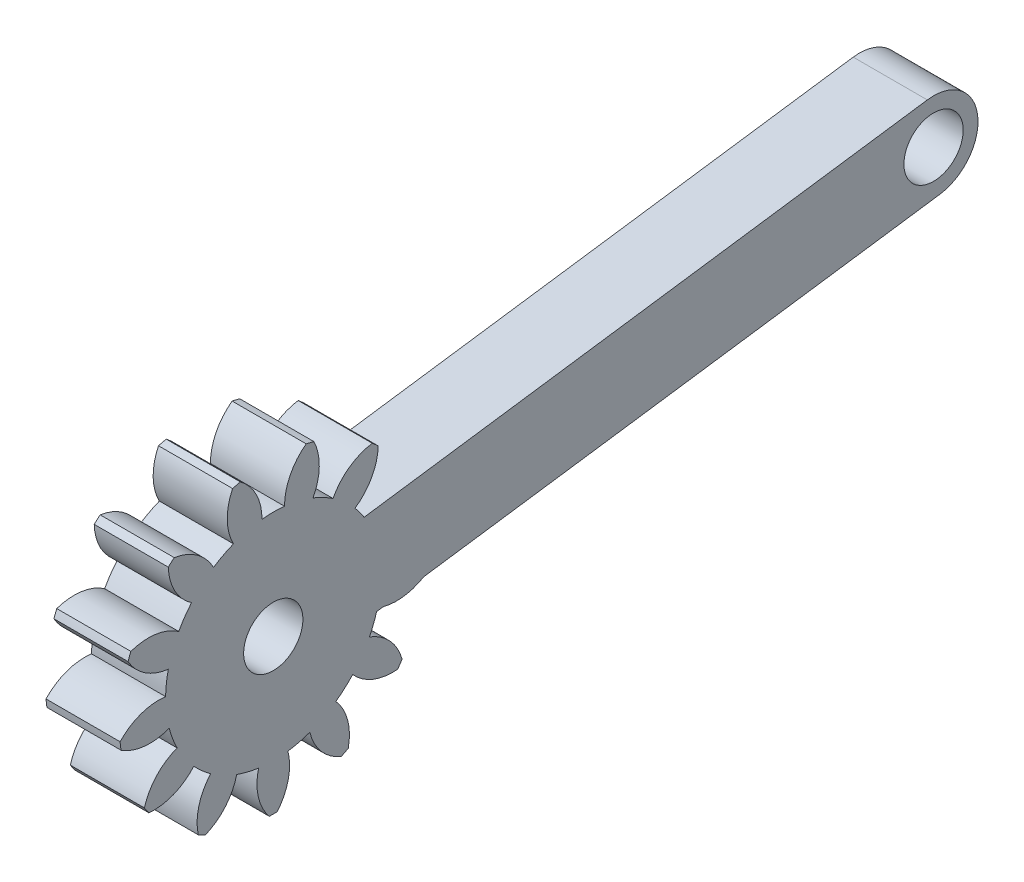
from build123d import *

# Parameters (mm, degrees)
SKETCH1_R           = 2
BOSS_EXTRUDE1_DEPTH = 5
SKETCH2_R           = 2
BOSS_EXTRUDE2_DEPTH = 5


with BuildPart() as part:
    # Sketch1 → Boss-Extrude1 (new body)
    with BuildSketch(Plane(origin=(-2.712826585, 0, 0), x_dir=(0, 0, -1), z_dir=(1, 0, 0))):
        with BuildLine():
            ThreePointArc((-81.47562753, 41.343615563), (-81.034251259, 39.725922602), (-79.907831624, 38.483778355))
            ThreePointArc((-79.907831624, 38.483778355), (-80.372835078, 37.880397724), (-80.772113271, 37.231650221))
            ThreePointArc((-80.772113271, 37.231650221), (-82.332972226, 37.844400456), (-84.002055602, 37.683452608))
            ThreePointArc((-84.002055602, 37.683452608), (-84.100262161, 37.43424746), (-84.192007076, 37.182591734))
            ThreePointArc((-84.192007076, 37.182591734), (-83.049408394, 35.955313535), (-81.474760125, 35.378922733))
            ThreePointArc((-81.474760125, 35.378922733), (-81.606095275, 34.628557837), (-81.65815056, 33.868566623))
            ThreePointArc((-81.65815056, 33.868566623), (-83.324981759, 33.685762686), (-84.728085497, 32.767588723))
            ThreePointArc((-84.728085497, 32.767588723), (-84.69923168, 32.50128966), (-84.663517521, 32.235823593))
            ThreePointArc((-84.663517521, 32.235823593), (-83.081452015, 31.6801148), (-81.419308055, 31.901521629))
            ThreePointArc((-81.419308055, 31.901521629), (-81.1868876, 31.176072024), (-80.879794738, 30.478941927))
            ThreePointArc((-80.879794738, 30.478941927), (-82.270747242, 29.542461997), (-83.086437186, 28.077404509))
            ThreePointArc((-83.086437186, 28.077404509), (-82.937133053, 27.855017437), (-82.782141503, 27.636556105))
            ThreePointArc((-82.782141503, 27.636556105), (-81.123041315, 27.879722907), (-79.754178815, 28.848205731))
            ThreePointArc((-79.754178815, 28.848205731), (-79.211247481, 28.313863177), (-78.615357745, 27.839298301))
            ThreePointArc((-78.615357745, 27.839298301), (-79.411781098, 26.363678645), (-79.45319251, 24.687364646))
            ThreePointArc((-79.45319251, 24.687364646), (-79.217641841, 24.559835763), (-78.978879596, 24.438426025))
            ThreePointArc((-78.978879596, 24.438426025), (-77.622824585, 25.424761837), (-76.860833445, 26.918452913))
            ThreePointArc((-76.860833445, 26.918452913), (-76.131770258, 26.697628851), (-75.383594806, 26.55434629))
            ThreePointArc((-75.383594806, 26.55434629), (-75.403038015, 24.877633587), (-74.660684041, 23.374086413))
            ThreePointArc((-74.660684041, 23.374086413), (-74.392848655, 23.370631049), (-74.125013268, 23.374086413))
            ThreePointArc((-74.125013268, 23.374086413), (-73.382659294, 24.877633587), (-73.402102503, 26.55434629))
            ThreePointArc((-73.402102503, 26.55434629), (-72.653927052, 26.697628851), (-71.924863864, 26.918452913))
            ThreePointArc((-71.924863864, 26.918452913), (-71.162872724, 25.424761837), (-69.806817713, 24.438426025))
            ThreePointArc((-69.806817713, 24.438426025), (-69.568055468, 24.559835763), (-69.332504799, 24.687364646))
            ThreePointArc((-69.332504799, 24.687364646), (-69.373916212, 26.363678645), (-70.170339564, 27.839298301))
            ThreePointArc((-70.170339564, 27.839298301), (-69.574449829, 28.313863177), (-69.031518494, 28.848205731))
            ThreePointArc((-69.031518494, 28.848205731), (-67.662655994, 27.879722907), (-66.003555806, 27.636556105))
            ThreePointArc((-66.003555806, 27.636556105), (-65.848564256, 27.855017437), (-65.699260124, 28.077404509))
            ThreePointArc((-65.699260124, 28.077404509), (-66.514950067, 29.542461997), (-67.905902571, 30.478941927))
            ThreePointArc((-67.905902571, 30.478941927), (-67.598809709, 31.176072024), (-67.366389254, 31.901521629))
            ThreePointArc((-67.366389254, 31.901521629), (-65.704245294, 31.6801148), (-64.122179788, 32.235823593))
            ThreePointArc((-64.122179788, 32.235823593), (-64.086465629, 32.50128966), (-64.057611812, 32.767588723))
            ThreePointArc((-64.057611812, 32.767588723), (-65.46071555, 33.685762686), (-67.12754675, 33.868566623))
            ThreePointArc((-67.12754675, 33.868566623), (-67.179602034, 34.628557837), (-67.310937184, 35.378922733))
            ThreePointArc((-67.310937184, 35.378922733), (-65.736288915, 35.955313535), (-64.593690233, 37.182591734))
            ThreePointArc((-64.593690233, 37.182591734), (-64.685435149, 37.43424746), (-64.783641707, 37.683452608))
            ThreePointArc((-64.783641707, 37.683452608), (-66.452725084, 37.844400456), (-68.013584038, 37.231650221))
            ThreePointArc((-68.013584038, 37.231650221), (-68.412862231, 37.880397724), (-68.877865686, 38.483778355))
            ThreePointArc((-68.877865686, 38.483778355), (-67.75144605, 39.725922602), (-67.31006978, 41.343615563))
            ThreePointArc((-67.31006978, 41.343615563), (-67.508256115, 41.523809654), (-67.711025111, 41.69883099))
            ThreePointArc((-67.711025111, 41.69883099), (-69.263721238, 41.065681511), (-70.361033972, 39.797750798))
            ThreePointArc((-70.361033972, 39.797750798), (-71.016065252, 40.186634356), (-71.708210323, 40.504803491))
            ThreePointArc((-71.708210323, 40.504803491), (-71.288068484, 42.128140906), (-71.64902861, 43.765654666))
            ThreePointArc((-71.64902861, 43.765654666), (-71.908254264, 43.833106827), (-72.169133764, 43.893849073))
            ThreePointArc((-72.169133764, 43.893849073), (-73.249738671, 42.611649181), (-73.632124061, 40.979005638))
            ThreePointArc((-73.632124061, 40.979005638), (-74.392848655, 41.018936713), (-75.153573248, 40.979005638))
            ThreePointArc((-75.153573248, 40.979005638), (-75.535958638, 42.611649181), (-76.616563545, 43.893849073))
            ThreePointArc((-76.616563545, 43.893849073), (-76.877443045, 43.833106827), (-77.1366687, 43.765654666))
            ThreePointArc((-77.1366687, 43.765654666), (-77.497628825, 42.128140906), (-77.077486986, 40.504803491))
            ThreePointArc((-77.077486986, 40.504803491), (-77.769632058, 40.186634356), (-78.424663337, 39.797750798))
            ThreePointArc((-78.424663337, 39.797750798), (-79.521976071, 41.065681511), (-81.074672198, 41.69883099))
            ThreePointArc((-81.074672198, 41.69883099), (-81.277441194, 41.523809654), (-81.47562753, 41.343615563))
        make_face()
        with Locations((-74.392848655, 33.752711127)):
            Circle(SKETCH1_R, mode=Mode.SUBTRACT)
    extrude(amount=-BOSS_EXTRUDE1_DEPTH)

    # Sketch2 → Boss-Extrude2 (add)
    with BuildSketch(Plane(origin=(-2.712826585, 0, 0), x_dir=(0, 0, -1), z_dir=(1, 0, 0))):
        with BuildLine():
            Line((-74.813866248, 36.72302158), (-30.259209457, 43.038285487))
            ThreePointArc((-30.259209457, 43.038285487), (-26.867881411, 40.488992628), (-29.41717427, 37.097664581))
            Line((-29.41717427, 37.097664581), (-73.971831061, 30.782400674))
            ThreePointArc((-73.971831061, 30.782400674), (-71.422538202, 34.173728721), (-74.813866248, 36.72302158))
        make_face()
        with Locations((-29.838191863, 40.067975034)):
            Circle(SKETCH2_R, mode=Mode.SUBTRACT)
    extrude(amount=-BOSS_EXTRUDE2_DEPTH)


solid = part.part
